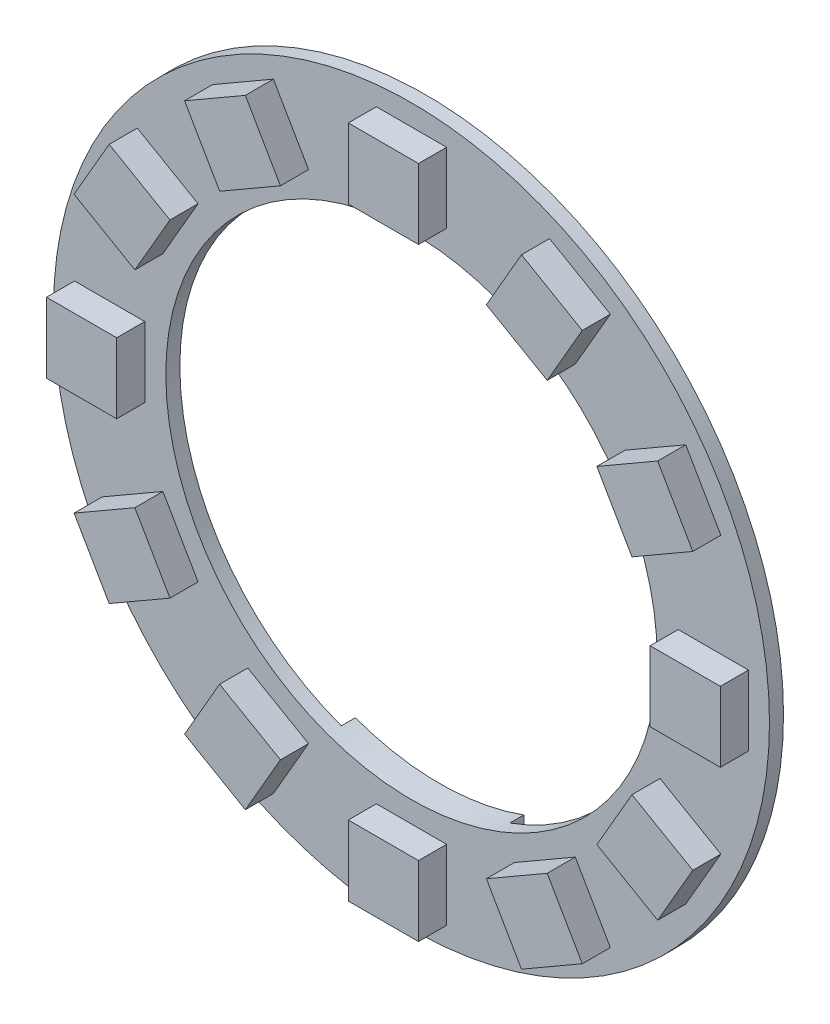
from build123d import *

# Parameters (mm, degrees)
SKIZZE1_R                       = 25.5
SKIZZE1_R_2                     = 17.5
AUFSATZ_LINEAR_AUSTRAGEN1_DEPTH = 1
AUFSATZ_LINEAR_AUSTRAGEN2_DEPTH = 1
SKIZZE3_W                       = 5
SKIZZE3_H                       = 5
AUFSATZ_LINEAR_AUSTRAGEN3_DEPTH = 2


with BuildPart() as part:
    # Skizze1 → Aufsatz-Linear austragen1 (new body)
    with BuildSketch(Plane.XY):
        Circle(SKIZZE1_R)
        Circle(SKIZZE1_R_2, mode=Mode.SUBTRACT)
    extrude(amount=AUFSATZ_LINEAR_AUSTRAGEN1_DEPTH)

    # Skizze2 → Aufsatz-Linear austragen2 (add)
    with BuildSketch(Plane(origin=(0, 0, 0), x_dir=(-1, 0, 0), z_dir=(0, 0, -1))):
        with BuildLine():
            Line((-6, -16.439282223), (-6, -24.784067463))
            ThreePointArc((-6, -24.784067463), (0, -25.5), (6, -24.784067463))
            Line((6, -24.784067463), (6, -16.439282223))
            ThreePointArc((6, -16.439282223), (0, -17.5), (-6, -16.439282223))
        make_face()
    extrude(amount=AUFSATZ_LINEAR_AUSTRAGEN2_DEPTH)

    # Skizze3 → Aufsatz-Linear austragen3 (add)
    with BuildSketch(Plane.XY.offset(1)):
        Polygon((-11.665063509, -15.204482672), (-14.165063509, -19.534609691), (-9.834936491, -22.034609691), (-7.334936491, -17.704482672), align=None)
        with Locations((0, -21.5)):
            Rectangle(SKIZZE3_W, SKIZZE3_H)
        Polygon((-17.704482672, -7.334936491), (-22.034609691, -9.834936491), (-19.534609691, -14.165063509), (-15.204482672, -11.665063509), align=None)
        with Locations((-21.5, 0)):
            Rectangle(SKIZZE3_W, SKIZZE3_H)
        Polygon((-15.204482672, 11.665063509), (-19.534609691, 14.165063509), (-22.034609691, 9.834936491), (-17.704482672, 7.334936491), align=None)
        Polygon((-7.334936491, 17.704482672), (-9.834936491, 22.034609691), (-14.165063509, 19.534609691), (-11.665063509, 15.204482672), align=None)
        with Locations((0, 21.5)):
            Rectangle(SKIZZE3_W, SKIZZE3_H)
        Polygon((11.665063509, 15.204482672), (14.165063509, 19.534609691), (9.834936491, 22.034609691), (7.334936491, 17.704482672), align=None)
        Polygon((17.704482672, 7.334936491), (22.034609691, 9.834936491), (19.534609691, 14.165063509), (15.204482672, 11.665063509), align=None)
        with Locations((21.5, 0)):
            Rectangle(SKIZZE3_W, SKIZZE3_H)
        Polygon((15.204482672, -11.665063509), (19.534609691, -14.165063509), (22.034609691, -9.834936491), (17.704482672, -7.334936491), align=None)
        Polygon((7.334936491, -17.704482672), (9.834936491, -22.034609691), (14.165063509, -19.534609691), (11.665063509, -15.204482672), align=None)
    extrude(amount=AUFSATZ_LINEAR_AUSTRAGEN3_DEPTH)


solid = part.part
